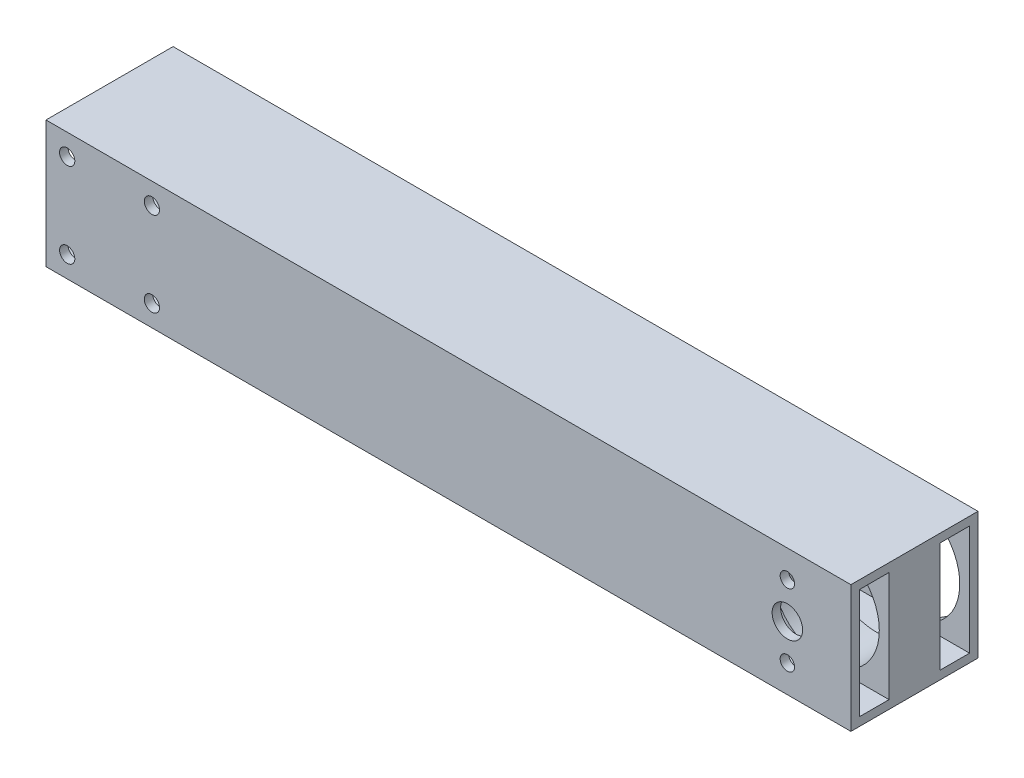
from build123d import *

# Parameters (mm, degrees)
SKETCH1_W                = 30
SKETCH1_H                = 30
SKETCH1_W_2              = 7
SKETCH1_H_2              = 26
BOSS_EXTRUDE3_DEPTH      = 110
BOSS_EXTRUDE3_DEPTH_BACK = 80
SKETCH6_R                = 12.7
CUT_EXTRUDE5_DEPTH       = 23
SKETCH8_R                = 3.6
SKETCH8_R_2              = 1.7
CUT_EXTRUDE6_DEPTH       = 17
SKETCH9_W                = 12
SKETCH9_H                = 26
CUT_EXTRUDE7_DEPTH       = 155
M3_CLEARANCE_HOLE1_D     = 3.6


with BuildPart() as part:
    # Sketch1 → Boss-Extrude3 (new body, two sides)
    with BuildSketch(Plane(origin=(0, 0, 0), x_dir=(0, 0, -1), z_dir=(1, 0, 0))) as boss_extrude3_sk:
        Rectangle(SKETCH1_W, SKETCH1_H)
        with Locations((-9.5, 0)):
            Rectangle(SKETCH1_W_2, SKETCH1_H_2, mode=Mode.SUBTRACT)
        with Locations((9.5, 0)):
            Rectangle(SKETCH1_W_2, SKETCH1_H_2, mode=Mode.SUBTRACT)
    extrude(amount=BOSS_EXTRUDE3_DEPTH)
    extrude(boss_extrude3_sk.sketch, amount=-BOSS_EXTRUDE3_DEPTH_BACK)

    # Sketch6 → Cut-Extrude5 (cut)
    with BuildSketch(Plane(origin=(0, 0, -15), x_dir=(-1, 0, 0), z_dir=(0, 0, -1))):
        with Locations((-95, 0)):
            Circle(SKETCH6_R)
    extrude(amount=-CUT_EXTRUDE5_DEPTH, mode=Mode.SUBTRACT)

    # Sketch8 → Cut-Extrude6 (cut)
    with BuildSketch(Plane.XY.offset(15)):
        with Locations((95, 0)):
            Circle(SKETCH8_R)
        with Locations((95, 8.5)):
            Circle(SKETCH8_R_2)
        with Locations((95, -8.5)):
            Circle(SKETCH8_R_2)
    extrude(amount=-CUT_EXTRUDE6_DEPTH, mode=Mode.SUBTRACT)

    # Sketch9 → Cut-Extrude7 (cut)
    with BuildSketch(Plane.ZY.offset(80)):
        Rectangle(SKETCH9_W, SKETCH9_H)
    extrude(amount=-CUT_EXTRUDE7_DEPTH, mode=Mode.SUBTRACT)

    # M3 Clearance Hole1 (through all)
    with Locations(Plane.XY.offset(15)):
        with Locations((-75, 10), (-75, -10), (-55, -10), (-55, 10)):
            Hole(M3_CLEARANCE_HOLE1_D / 2)


solid = part.part
